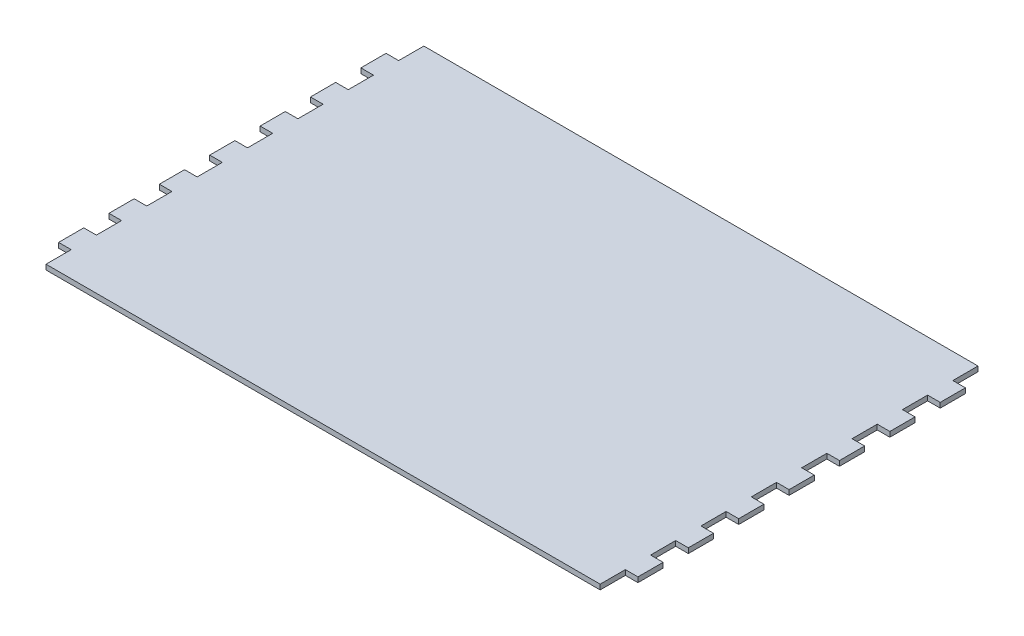
from build123d import *

# Parameters (mm, degrees)
BOSS_EXTRUDE1_DEPTH = 2.54


with BuildPart() as part:
    # Sketch1 → Boss-Extrude1 (new body)
    with BuildSketch(Plane(origin=(0, 0, 0), x_dir=(1, 0, 0), z_dir=(0, 1, 0))):
        Polygon((0, 0), (279.4, 0), (279.4, -12.7), (285.75, -12.7), (285.75, -25.4), (279.4, -25.4), (279.4, -38.1), (285.75, -38.1), (285.75, -50.8), (279.4, -50.8), (279.4, -63.5), (285.75, -63.5), (285.75, -76.2), (279.4, -76.2), (279.4, -88.9), (285.75, -88.9), (285.75, -101.6), (279.4, -101.6), (279.4, -114.3), (285.75, -114.3), (285.75, -127), (279.4, -127), (279.4, -139.7), (285.75, -139.7), (285.75, -152.4), (279.4, -152.4), (279.4, -165.1), (285.75, -165.1), (285.75, -177.8), (279.4, -177.8), (279.4, -190.5), (0, -190.5), (0, -177.8), (-6.35, -177.8), (-6.35, -165.1), (0, -165.1), (0, -152.4), (-6.35, -152.4), (-6.35, -139.7), (0, -139.7), (0, -127), (-6.35, -127), (-6.35, -114.3), (0, -114.3), (0, -101.6), (-6.35, -101.6), (-6.35, -88.9), (0, -88.9), (0, -76.2), (-6.35, -76.2), (-6.35, -63.5), (0, -63.5), (0, -50.8), (-6.35, -50.8), (-6.35, -38.1), (0, -38.1), (0, -25.4), (-6.35, -25.4), (-6.35, -12.7), (0, -12.7), align=None)
    extrude(amount=BOSS_EXTRUDE1_DEPTH)


solid = part.part
